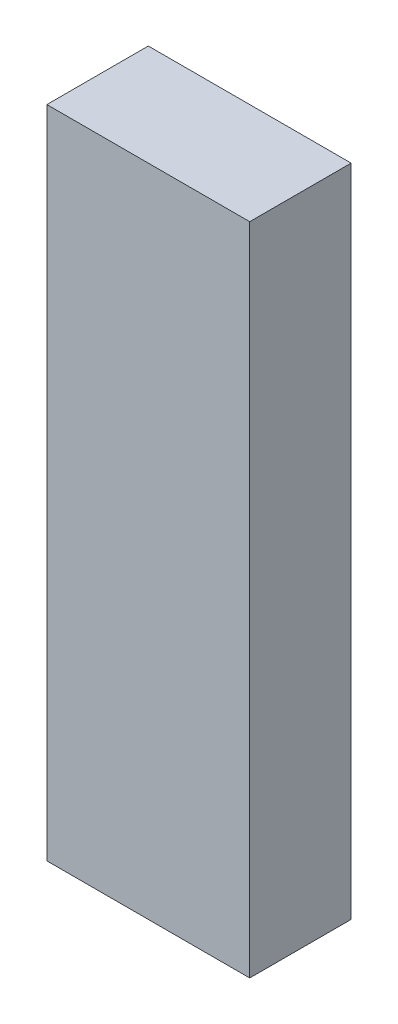
from build123d import *

# Parameters (mm, degrees)
SKETCH1_W           = 48
SKETCH1_H           = 155
BOSS_EXTRUDE1_DEPTH = 24


with BuildPart() as part:
    # Sketch1 → Boss-Extrude1 (new body)
    with BuildSketch(Plane.XY):
        Rectangle(SKETCH1_W, SKETCH1_H)
    extrude(amount=BOSS_EXTRUDE1_DEPTH)


solid = part.part
